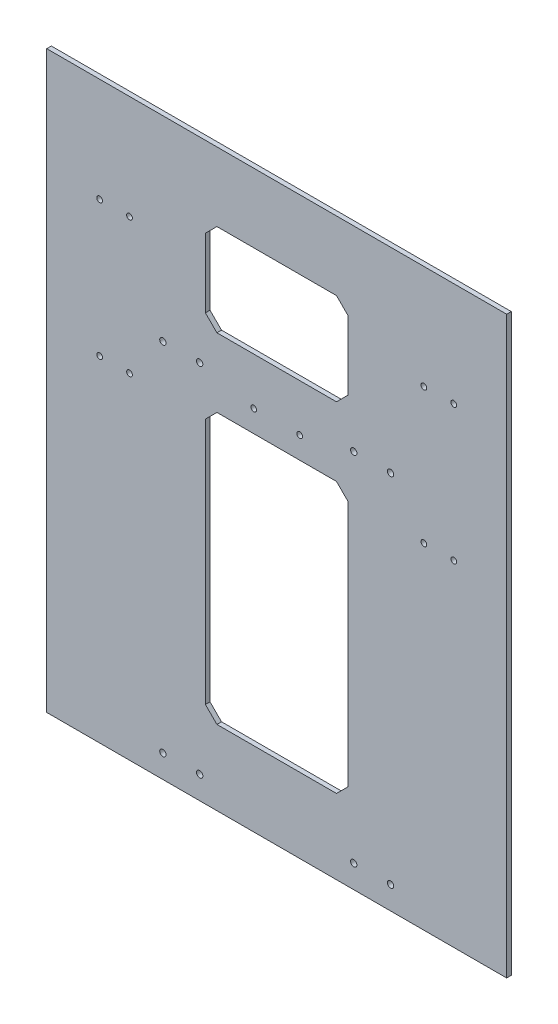
from build123d import *

# Parameters (mm, degrees)
SKETCH1_W           = 400
SKETCH1_H           = 500
BOSS_EXTRUDE1_DEPTH = 4
SKETCH2_W           = 124
SKETCH2_H           = 235
CUT_EXTRUDE1_DEPTH  = 5
SKETCH4_R           = 2.75
CUT_EXTRUDE3_DEPTH  = 10
SKETCH5_R           = 2.5
CUT_EXTRUDE4_DEPTH  = 5
SKETCH6_R           = 2.5
CUT_EXTRUDE5_DEPTH  = 4
SKETCH7_R           = 2.75
CUT_EXTRUDE6_DEPTH  = 4
SKETCH9_W           = 124
SKETCH9_H           = 80
CUT_EXTRUDE9_DEPTH  = 4
CHAMFER1_SIZE       = 10


with BuildPart() as part:
    # Sketch1 → Boss-Extrude1 (new body)
    with BuildSketch(Plane.XY):
        with Locations((200, 250)):
            Rectangle(SKETCH1_W, SKETCH1_H)
    extrude(amount=BOSS_EXTRUDE1_DEPTH)

    # Sketch2 → Cut-Extrude1 (cut, through all)
    with BuildSketch(Plane.XY.offset(4)):
        with Locations((200, 182.5)):
            Rectangle(SKETCH2_W, SKETCH2_H)
    extrude(amount=-CUT_EXTRUDE1_DEPTH, mode=Mode.SUBTRACT)

    # Sketch4 → Cut-Extrude3 (cut)
    with BuildSketch(Plane.XY.offset(4)):
        with Locations((299, 330)):
            Circle(SKETCH4_R)
        with Locations((267, 330)):
            Circle(SKETCH4_R)
        with Locations((133, 330)):
            Circle(SKETCH4_R)
        with Locations((101, 330)):
            Circle(SKETCH4_R)
    extrude(amount=-CUT_EXTRUDE3_DEPTH, mode=Mode.SUBTRACT)

    # Sketch5 → Cut-Extrude4 (cut, through all)
    with BuildSketch(Plane.XY.offset(4)):
        with Locations((180, 319)):
            Circle(SKETCH5_R)
        with Locations((220, 319)):
            Circle(SKETCH5_R)
    extrude(amount=-CUT_EXTRUDE4_DEPTH, mode=Mode.SUBTRACT)

    # Sketch6 → Cut-Extrude5 (cut)
    with BuildSketch(Plane.XY.offset(4)):
        with Locations((72, 409.5)):
            Circle(SKETCH6_R)
        with Locations((46, 409.5)):
            Circle(SKETCH6_R)
        with Locations((72, 291.5)):
            Circle(SKETCH6_R)
        with Locations((46, 291.5)):
            Circle(SKETCH6_R)
        with Locations((328, 291.5)):
            Circle(SKETCH6_R)
        with Locations((354, 291.5)):
            Circle(SKETCH6_R)
        with Locations((328, 409.5)):
            Circle(SKETCH6_R)
        with Locations((354, 409.5)):
            Circle(SKETCH6_R)
    extrude(amount=-CUT_EXTRUDE5_DEPTH, mode=Mode.SUBTRACT)

    # Sketch7 → Cut-Extrude6 (cut)
    with BuildSketch(Plane(origin=(0, 0, 0), x_dir=(-1, 0, 0), z_dir=(0, 0, -1))):
        with Locations((-267, 20)):
            Circle(SKETCH7_R)
        with Locations((-299, 20)):
            Circle(SKETCH7_R)
        with Locations((-133, 20)):
            Circle(SKETCH7_R)
        with Locations((-101, 20)):
            Circle(SKETCH7_R)
    extrude(amount=-CUT_EXTRUDE6_DEPTH, mode=Mode.SUBTRACT)

    # Sketch9 → Cut-Extrude9 (cut)
    with BuildSketch(Plane(origin=(0, 0, 0), x_dir=(-1, 0, 0), z_dir=(0, 0, -1))):
        with Locations((-200, 400)):
            Rectangle(SKETCH9_W, SKETCH9_H)
    extrude(amount=-CUT_EXTRUDE9_DEPTH, mode=Mode.SUBTRACT)

    # Chamfer1
    chamfer1_edges = [part.edges().sort_by_distance(p)[0] for p in [
        (138, 440, 2),
        (138, 360, 2),
        (262, 360, 2),
        (262, 440, 2),
        (138, 300, 2),
        (262, 300, 2),
        (262, 65, 2),
        (138, 65, 2),
    ]]
    chamfer(chamfer1_edges, length=CHAMFER1_SIZE)


solid = part.part
